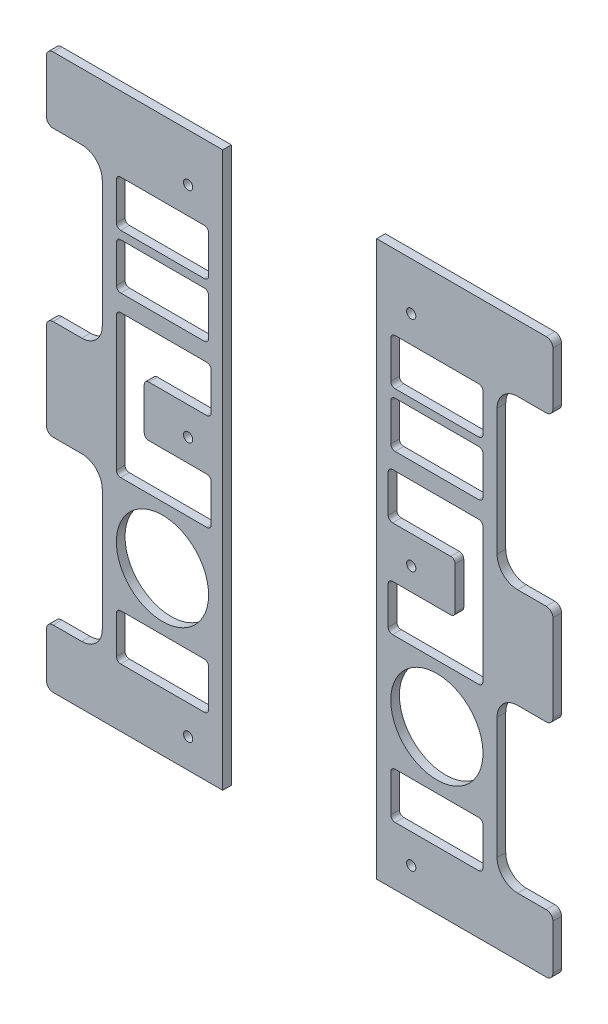
from build123d import *

# Parameters (mm, degrees)
SKETCH2_R           = 50.8
SKETCH2_R_2         = 5.08
BOSS_EXTRUDE1_DEPTH = 9.525


with BuildPart() as part:
    # Sketch2 → Boss-Extrude1 (new body)
    with BuildSketch(Plane.XY):
        with BuildLine():
            Line((84.797616832, -24.249572544), (218.42106791, -24.249572544))
            Line((218.42106791, -24.249572544), (271.672277076, -24.249572544))
            ThreePointArc((271.672277076, -24.249572544), (276.852146452, -26.395144691), (278.997718599, -31.575014067))
            Line((278.997718599, -31.575014067), (278.997718599, -89.760973963))
            ThreePointArc((278.997718599, -89.760973963), (276.852146452, -94.940843339), (271.672277076, -97.086415486))
            Line((271.672277076, -97.086415486), (240.092921247, -97.086415486))
            ThreePointArc((240.092921247, -97.086415486), (224.136744526, -103.695680288), (217.527479724, -119.651857009))
            Line((217.527479724, -119.651857009), (217.527479724, -258.987113052))
            ThreePointArc((217.527479724, -258.987113052), (224.136744526, -274.943289773), (240.092921247, -281.552554575))
            Line((240.092921247, -281.552554575), (271.672277076, -281.552554575))
            ThreePointArc((271.672277076, -281.552554575), (276.852146452, -283.698126722), (278.997718599, -288.877996098))
            Line((278.997718599, -288.877996098), (278.997718599, -384.592162016))
            ThreePointArc((278.997718599, -384.592162016), (276.852146452, -389.772031392), (271.672277076, -391.917603539))
            Line((271.672277076, -391.917603539), (240.092921247, -391.917603539))
            ThreePointArc((240.092921247, -391.917603539), (224.136744526, -398.526868341), (217.527479724, -414.483045062))
            Line((217.527479724, -414.483045062), (217.527479724, -548.445742861))
            ThreePointArc((217.527479724, -548.445742861), (224.148623829, -564.430598757), (240.133479724, -571.051742861))
            Line((240.133479724, -571.051742861), (271.631718599, -571.051742861))
            ThreePointArc((271.631718599, -571.051742861), (276.840267149, -573.209194311), (278.997718599, -578.417742861))
            Line((278.997718599, -578.417742861), (278.997718599, -628.050644154))
            ThreePointArc((278.997718599, -628.050644154), (276.840267149, -633.259192705), (271.631718599, -635.416644154))
            Line((271.631718599, -635.416644154), (84.797616832, -635.416644154))
            Line((84.797616832, -635.416644154), (84.797616832, -571.048379504))
            Line((84.797616832, -571.048379504), (84.797616832, -342.455106218))
            Line((84.797616832, -342.455106218), (84.797616832, -298.45))
            Line((84.797616832, -298.45), (84.797616832, -46.093485722))
            Line((84.797616832, -46.093485722), (84.797616832, -24.249572544))
        make_face()
        with Locations((151.162548278, -456.751742861)):
            Circle(SKETCH2_R, mode=Mode.SUBTRACT)
        with Locations((122.897616832, -76.719251329)):
            Circle(SKETCH2_R_2, mode=Mode.SUBTRACT)
        with Locations((122.897616832, -317.5)):
            Circle(SKETCH2_R_2, mode=Mode.SUBTRACT)
        with Locations((122.897616832, -603.25)):
            Circle(SKETCH2_R_2, mode=Mode.SUBTRACT)
        with BuildLine():
            Line((171.255097836, -291.357184384), (171.255097836, -337.666301338))
            ThreePointArc((171.255097836, -337.666301338), (169.853474465, -341.05011949), (166.469656313, -342.451742861))
            Line((166.469656313, -342.451742861), (102.282017603, -342.451742861))
            ThreePointArc((102.282017603, -342.451742861), (98.898199451, -343.853366232), (97.49657608, -347.237184384))
            Line((97.49657608, -347.237184384), (97.49657608, -388.466301338))
            ThreePointArc((97.49657608, -388.466301338), (98.898199451, -391.85011949), (102.282017603, -393.251742861))
            Line((102.282017603, -393.251742861), (197.177106755, -393.251742861))
            ThreePointArc((197.177106755, -393.251742861), (200.560924907, -391.85011949), (201.962548278, -388.466301338))
            Line((201.962548278, -388.466301338), (201.962548278, -357.508699937))
            Line((201.962548278, -357.508699937), (201.962548278, -317.5))
            Line((201.962548278, -317.5), (201.962548278, -240.557184384))
            ThreePointArc((201.962548278, -240.557184384), (200.560924907, -237.173366232), (197.177106755, -235.771742861))
            Line((197.177106755, -235.771742861), (102.282017603, -235.771742861))
            ThreePointArc((102.282017603, -235.771742861), (98.898199451, -237.173366232), (97.49657608, -240.557184384))
            Line((97.49657608, -240.557184384), (97.49657608, -281.786301338))
            ThreePointArc((97.49657608, -281.786301338), (98.898199451, -285.17011949), (102.282017603, -286.571742861))
            Line((102.282017603, -286.571742861), (166.469656313, -286.571742861))
            ThreePointArc((166.469656313, -286.571742861), (169.853474465, -287.973366232), (171.255097836, -291.357184384))
        make_face(mode=Mode.SUBTRACT)
        with BuildLine():
            Line((105.147989801, -520.251742861), (197.177106755, -520.251742861))
            ThreePointArc((197.177106755, -520.251742861), (200.560924907, -521.653366232), (201.962548278, -525.037184384))
            Line((201.962548278, -525.037184384), (201.962548278, -566.266301338))
            ThreePointArc((201.962548278, -566.266301338), (200.560924907, -569.65011949), (197.177106755, -571.051742861))
            Line((197.177106755, -571.051742861), (105.147989801, -571.051742861))
            ThreePointArc((105.147989801, -571.051742861), (101.764171649, -569.65011949), (100.362548278, -566.266301338))
            Line((100.362548278, -566.266301338), (100.362548278, -525.037184384))
            ThreePointArc((100.362548278, -525.037184384), (101.764171649, -521.653366232), (105.147989801, -520.251742861))
        make_face(mode=Mode.SUBTRACT)
        with BuildLine():
            Line((105.147989801, -166.24725812), (197.177106755, -166.24725812))
            ThreePointArc((197.177106755, -166.24725812), (200.560924907, -167.648881491), (201.962548278, -171.032699643))
            Line((201.962548278, -171.032699643), (201.962548278, -212.261816598))
            ThreePointArc((201.962548278, -212.261816598), (200.560924907, -215.645634749), (197.177106755, -217.04725812))
            Line((197.177106755, -217.04725812), (105.147989801, -217.04725812))
            ThreePointArc((105.147989801, -217.04725812), (101.764171649, -215.645634749), (100.362548278, -212.261816598))
            Line((100.362548278, -212.261816598), (100.362548278, -171.032699643))
            ThreePointArc((100.362548278, -171.032699643), (101.764171649, -167.648881491), (105.147989801, -166.24725812))
        make_face(mode=Mode.SUBTRACT)
        with BuildLine():
            Line((105.147989801, -106.458623468), (197.177106755, -106.458623468))
            ThreePointArc((197.177106755, -106.458623468), (200.560924907, -107.860246839), (201.962548278, -111.244064991))
            Line((201.962548278, -111.244064991), (201.962548278, -152.473181945))
            ThreePointArc((201.962548278, -152.473181945), (200.560924907, -155.857000097), (197.177106755, -157.258623468))
            Line((197.177106755, -157.258623468), (105.147989801, -157.258623468))
            ThreePointArc((105.147989801, -157.258623468), (101.764171649, -155.857000097), (100.362548278, -152.473181945))
            Line((100.362548278, -152.473181945), (100.362548278, -111.244064991))
            ThreePointArc((100.362548278, -111.244064991), (101.764171649, -107.860246839), (105.147989801, -106.458623468))
        make_face(mode=Mode.SUBTRACT)
    extrude(amount=BOSS_EXTRUDE1_DEPTH)


with BuildPart() as body_2:
    # Mirror4: mirrored copy
    add(part.part.mirror(Plane(origin=(0, 0, 0), x_dir=(0, 0, 1), z_dir=(1, 0, 0))))


solid = Compound([part.part, body_2.part])
